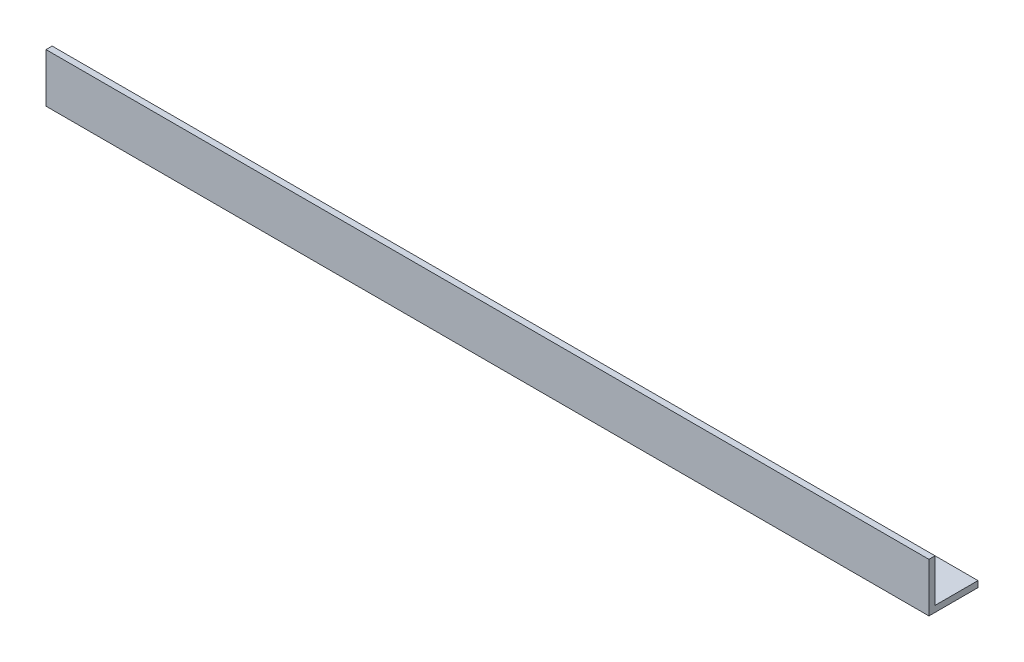
from build123d import *

# Parameters (mm, degrees)
BOSS_EXTRUDE1_DEPTH = 228.6


with BuildPart() as part:
    # Sketch1 → Boss-Extrude1 (new body, symmetric)
    with BuildSketch(Plane(origin=(0, 0, 0), x_dir=(0, 0, -1), z_dir=(1, 0, 0))):
        Polygon((0, 0), (0, 25.4), (3.175, 25.4), (3.175, 3.175), (25.4, 3.175), (25.4, 0), align=None)
    extrude(amount=BOSS_EXTRUDE1_DEPTH, both=True)


solid = part.part
